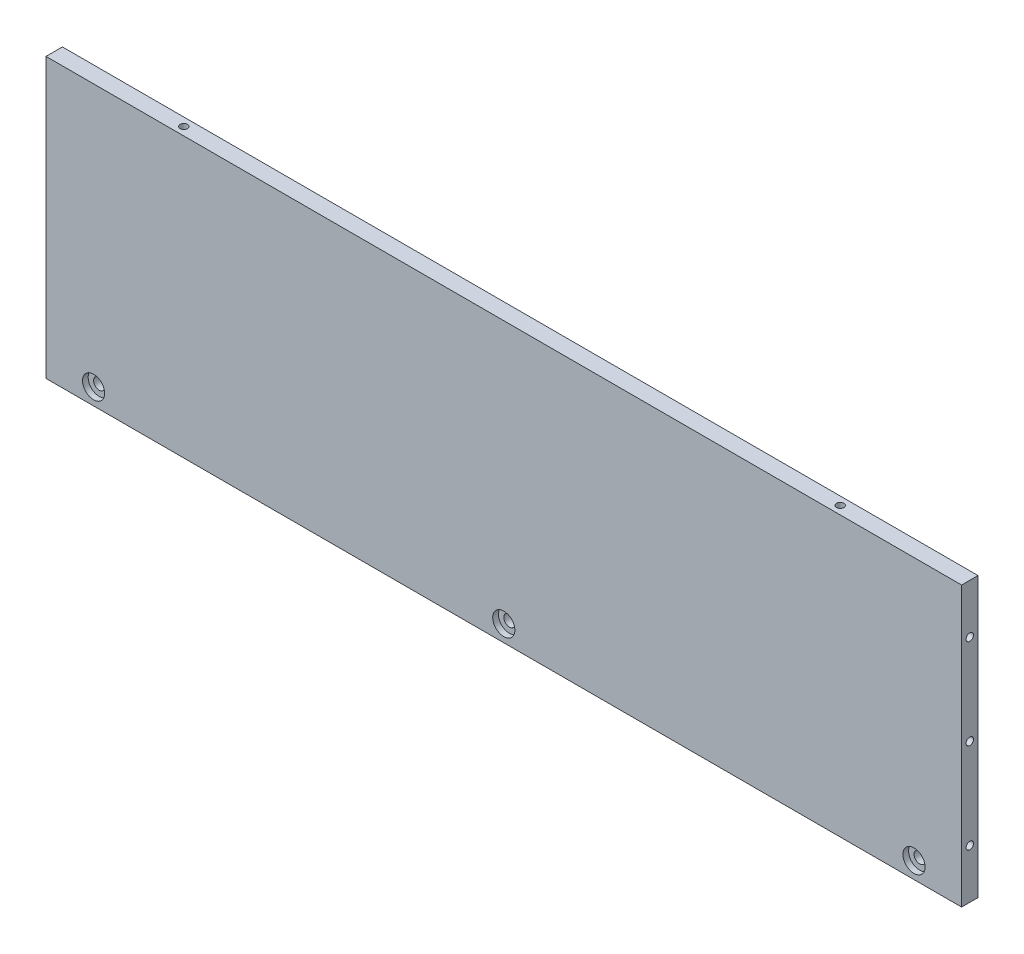
from build123d import *

# Parameters (mm, degrees)
SKETCH1_W                                           = 279
SKETCH1_H                                           = 85
BOSS_EXTRUDE1_DEPTH                                 = 5
CBORE_FOR_4_BINDING_HEAD_MACHINE_SCREW1_D           = 3.4544
CBORE_FOR_4_BINDING_HEAD_MACHINE_SCREW1_CBORE_D     = 6.74624
CBORE_FOR_4_BINDING_HEAD_MACHINE_SCREW1_CBORE_DEPTH = 1.7272
F_4_40_TAPPED_HOLE1_D                               = 2.2606
F_4_40_TAPPED_HOLE1_DEPTH                           = 7.6
F_4_40_TAPPED_HOLE1_TIP                             = 0.679152758
F_4_40_TAPPED_HOLE2_D                               = 2.2606
F_4_40_TAPPED_HOLE2_DEPTH                           = 7.6
F_4_40_TAPPED_HOLE2_TIP                             = 0.679152758
F_4_40_TAPPED_HOLE3_D                               = 2.2606
F_4_40_TAPPED_HOLE3_DEPTH                           = 7.6
F_4_40_TAPPED_HOLE3_TIP                             = 0.679152758


with BuildPart() as part:
    # Sketch1 → Boss-Extrude1 (new body)
    with BuildSketch(Plane.XY):
        with Locations((8.503783102, 35.532786885)):
            Rectangle(SKETCH1_W, SKETCH1_H)
    extrude(amount=BOSS_EXTRUDE1_DEPTH)

    # CBORE for #4 Binding Head Machine Screw1 (through all)
    with Locations(Plane.XY.offset(5)):
        with Locations((-116.496216898, -1.967213115), (8.503783102, -1.967213115), (133.503783102, -1.967213115)):
            CounterBoreHole(CBORE_FOR_4_BINDING_HEAD_MACHINE_SCREW1_D / 2, CBORE_FOR_4_BINDING_HEAD_MACHINE_SCREW1_CBORE_D / 2, CBORE_FOR_4_BINDING_HEAD_MACHINE_SCREW1_CBORE_DEPTH)

    # #4-40 Tapped Hole1
    with Locations(Plane.ZY.offset(130.996216898)):
        with Locations((2.5, 63.032786885), (2.5, 35.532786885), (2.5, 8.032786885)):
            Hole(F_4_40_TAPPED_HOLE1_D / 2, depth=F_4_40_TAPPED_HOLE1_DEPTH)
            with Locations((0, 0, -(F_4_40_TAPPED_HOLE1_DEPTH + F_4_40_TAPPED_HOLE1_TIP / 2))):  # 118° drill point
                Cone(0, F_4_40_TAPPED_HOLE1_D / 2, F_4_40_TAPPED_HOLE1_TIP, mode=Mode.SUBTRACT)

    # #4-40 Tapped Hole2
    with Locations(Plane(origin=(148.003783102, 0, 0), x_dir=(0, 0, -1), z_dir=(1, 0, 0))):
        with Locations((-2.5, 63.032786885), (-2.5, 35.532786885), (-2.5, 8.032786885)):
            Hole(F_4_40_TAPPED_HOLE2_D / 2, depth=F_4_40_TAPPED_HOLE2_DEPTH)
            with Locations((0, 0, -(F_4_40_TAPPED_HOLE2_DEPTH + F_4_40_TAPPED_HOLE2_TIP / 2))):  # 118° drill point
                Cone(0, F_4_40_TAPPED_HOLE2_D / 2, F_4_40_TAPPED_HOLE2_TIP, mode=Mode.SUBTRACT)

    # #4-40 Tapped Hole3
    with Locations(Plane(origin=(0, 78.032786885, 0), x_dir=(1, 0, 0), z_dir=(0, 1, 0))):
        with Locations((-91.496216898, -2.5), (108.503783102, -2.5)):
            Hole(F_4_40_TAPPED_HOLE3_D / 2, depth=F_4_40_TAPPED_HOLE3_DEPTH)
            with Locations((0, 0, -(F_4_40_TAPPED_HOLE3_DEPTH + F_4_40_TAPPED_HOLE3_TIP / 2))):  # 118° drill point
                Cone(0, F_4_40_TAPPED_HOLE3_D / 2, F_4_40_TAPPED_HOLE3_TIP, mode=Mode.SUBTRACT)


solid = part.part
